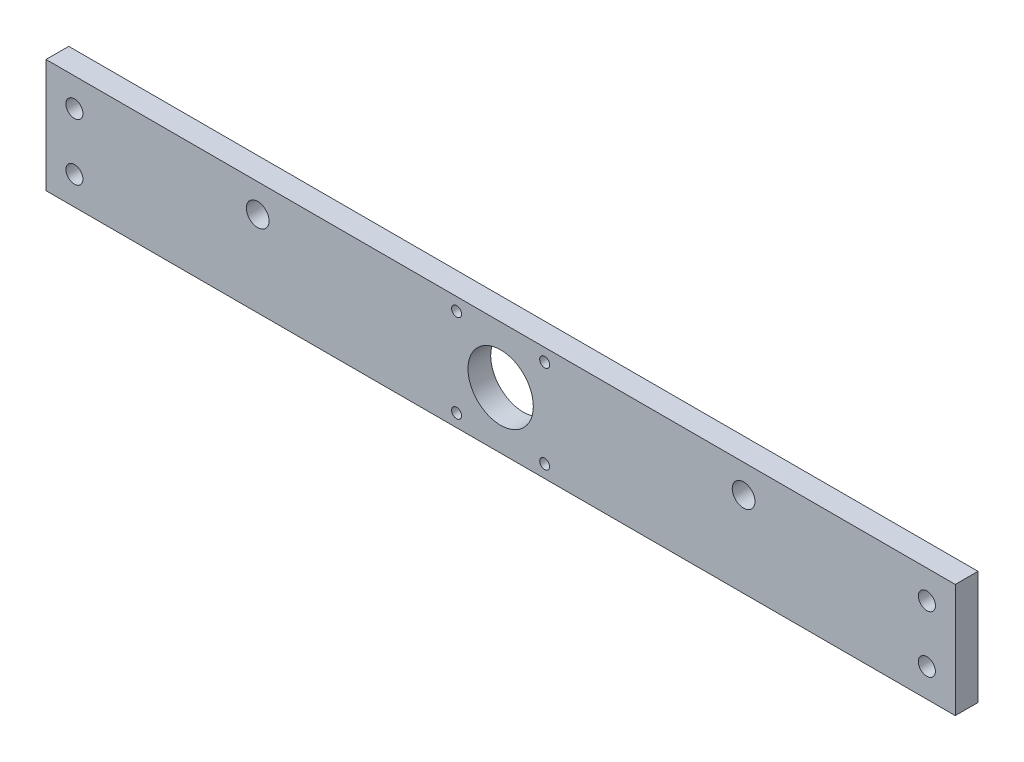
from build123d import *

# Parameters (mm, degrees)
SKETCH1_W           = 320
SKETCH1_H           = 40
BOSS_EXTRUDE1_DEPTH = 8
CUT_EXTRUDE1_REACH  = 10
SKETCH2_R           = 3
CUT_EXTRUDE2_REACH  = 10
SKETCH3_R           = 4
SKETCH3_R_2         = 11.5
CUT_EXTRUDE3_REACH  = 10
SKETCH4_R           = 1.75


with BuildPart() as part:
    # Sketch1 → Boss-Extrude1 (new body)
    with BuildSketch(Plane.XY):
        Rectangle(SKETCH1_W, SKETCH1_H)
    extrude(amount=BOSS_EXTRUDE1_DEPTH)

    # Sketch2 → Cut-Extrude1 (cut, up to next)
    with BuildSketch(Plane.XY.offset(8), mode=Mode.PRIVATE) as cut_extrude1_sk1:
        with Locations((-150, 10)):
            Circle(SKETCH2_R)
    cut_extrude1_tool1 = extrude(cut_extrude1_sk1.sketch, amount=-CUT_EXTRUDE1_REACH, mode=Mode.PRIVATE) & part.part
    add(cut_extrude1_tool1.solids().sort_by_distance((-150, 10, 8))[0], mode=Mode.SUBTRACT)
    # Sketch2 → Cut-Extrude1 (cut, up to next)
    with BuildSketch(Plane.XY.offset(8), mode=Mode.PRIVATE) as cut_extrude1_sk2:
        with Locations((-150, -10)):
            Circle(SKETCH2_R)
    cut_extrude1_tool2 = extrude(cut_extrude1_sk2.sketch, amount=-CUT_EXTRUDE1_REACH, mode=Mode.PRIVATE) & part.part
    add(cut_extrude1_tool2.solids().sort_by_distance((-150, -10, 8))[0], mode=Mode.SUBTRACT)
    # Sketch2 → Cut-Extrude1 (cut, up to next)
    with BuildSketch(Plane.XY.offset(8), mode=Mode.PRIVATE) as cut_extrude1_sk3:
        with Locations((150, -10)):
            Circle(SKETCH2_R)
    cut_extrude1_tool3 = extrude(cut_extrude1_sk3.sketch, amount=-CUT_EXTRUDE1_REACH, mode=Mode.PRIVATE) & part.part
    add(cut_extrude1_tool3.solids().sort_by_distance((150, -10, 8))[0], mode=Mode.SUBTRACT)
    # Sketch2 → Cut-Extrude1 (cut, up to next)
    with BuildSketch(Plane.XY.offset(8), mode=Mode.PRIVATE) as cut_extrude1_sk4:
        with Locations((150, 10)):
            Circle(SKETCH2_R)
    cut_extrude1_tool4 = extrude(cut_extrude1_sk4.sketch, amount=-CUT_EXTRUDE1_REACH, mode=Mode.PRIVATE) & part.part
    add(cut_extrude1_tool4.solids().sort_by_distance((150, 10, 8))[0], mode=Mode.SUBTRACT)

    # Sketch3 → Cut-Extrude2 (cut, up to next)
    with BuildSketch(Plane.XY.offset(8), mode=Mode.PRIVATE) as cut_extrude2_sk1:
        with Locations((-85.5, 10)):
            Circle(SKETCH3_R)
    cut_extrude2_tool1 = extrude(cut_extrude2_sk1.sketch, amount=-CUT_EXTRUDE2_REACH, mode=Mode.PRIVATE) & part.part
    add(cut_extrude2_tool1.solids().sort_by_distance((-85.5, 10, 8))[0], mode=Mode.SUBTRACT)
    # Sketch3 → Cut-Extrude2 (cut, up to next)
    with BuildSketch(Plane.XY.offset(8), mode=Mode.PRIVATE) as cut_extrude2_sk2:
        with Locations((85.5, 10)):
            Circle(SKETCH3_R)
    cut_extrude2_tool2 = extrude(cut_extrude2_sk2.sketch, amount=-CUT_EXTRUDE2_REACH, mode=Mode.PRIVATE) & part.part
    add(cut_extrude2_tool2.solids().sort_by_distance((85.5, 10, 8))[0], mode=Mode.SUBTRACT)
    # Sketch3 → Cut-Extrude2 (cut, up to next)
    with BuildSketch(Plane.XY.offset(8), mode=Mode.PRIVATE) as cut_extrude2_sk3:
        Circle(SKETCH3_R_2)
    cut_extrude2_tool3 = extrude(cut_extrude2_sk3.sketch, amount=-CUT_EXTRUDE2_REACH, mode=Mode.PRIVATE) & part.part
    add(cut_extrude2_tool3.solids().sort_by_distance((0, 0, 8))[0], mode=Mode.SUBTRACT)

    # Sketch4 → Cut-Extrude3 (cut, up to next)
    with BuildSketch(Plane.XY.offset(8), mode=Mode.PRIVATE) as cut_extrude3_sk1:
        with Locations((-15.5, 15.5)):
            Circle(SKETCH4_R)
    cut_extrude3_tool1 = extrude(cut_extrude3_sk1.sketch, amount=-CUT_EXTRUDE3_REACH, mode=Mode.PRIVATE) & part.part
    add(cut_extrude3_tool1.solids().sort_by_distance((-15.5, 15.5, 8))[0], mode=Mode.SUBTRACT)
    # Sketch4 → Cut-Extrude3 (cut, up to next)
    with BuildSketch(Plane.XY.offset(8), mode=Mode.PRIVATE) as cut_extrude3_sk2:
        with Locations((15.5, 15.5)):
            Circle(SKETCH4_R)
    cut_extrude3_tool2 = extrude(cut_extrude3_sk2.sketch, amount=-CUT_EXTRUDE3_REACH, mode=Mode.PRIVATE) & part.part
    add(cut_extrude3_tool2.solids().sort_by_distance((15.5, 15.5, 8))[0], mode=Mode.SUBTRACT)
    # Sketch4 → Cut-Extrude3 (cut, up to next)
    with BuildSketch(Plane.XY.offset(8), mode=Mode.PRIVATE) as cut_extrude3_sk3:
        with Locations((-15.5, -15.5)):
            Circle(SKETCH4_R)
    cut_extrude3_tool3 = extrude(cut_extrude3_sk3.sketch, amount=-CUT_EXTRUDE3_REACH, mode=Mode.PRIVATE) & part.part
    add(cut_extrude3_tool3.solids().sort_by_distance((-15.5, -15.5, 8))[0], mode=Mode.SUBTRACT)
    # Sketch4 → Cut-Extrude3 (cut, up to next)
    with BuildSketch(Plane.XY.offset(8), mode=Mode.PRIVATE) as cut_extrude3_sk4:
        with Locations((15.5, -15.5)):
            Circle(SKETCH4_R)
    cut_extrude3_tool4 = extrude(cut_extrude3_sk4.sketch, amount=-CUT_EXTRUDE3_REACH, mode=Mode.PRIVATE) & part.part
    add(cut_extrude3_tool4.solids().sort_by_distance((15.5, -15.5, 8))[0], mode=Mode.SUBTRACT)


solid = part.part
